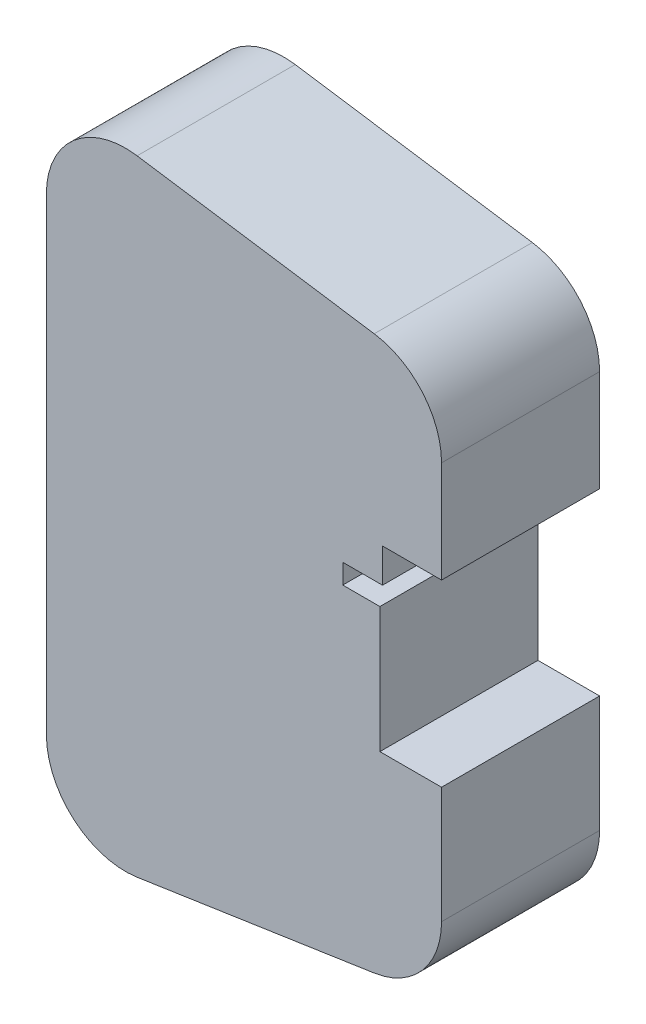
from build123d import *

# Parameters (mm, degrees)
BOSS_EXTRUDE1_DEPTH = 20
SKETCH5_W           = 9
SKETCH5_H           = 1.454272164
CUT_EXTRUDE4_DEPTH  = 10
SKETCH6_R           = 0.5
CUT_EXTRUDE5_DEPTH  = 5
CUT_EXTRUDE6_DEPTH  = 21
SKETCH11_R          = 1
CUT_EXTRUDE7_DEPTH  = 5


with BuildPart() as part:
    # Sketch1 → Boss-Extrude1 (new body)
    with BuildSketch(Plane.XY):
        with BuildLine():
            Line((0, 29.638125792), (0, -29.638125792))
            ThreePointArc((0, -29.638125792), (3.474436626, -37.215527896), (11.483404529, -39.527489321))
            Line((11.483404529, -39.527489321), (41.483404529, -35.027489321))
            ThreePointArc((41.483404529, -35.027489321), (47.577402104, -31.663689166), (50, -25.138125792))
            Line((50, -25.138125792), (50, 25.138125792))
            ThreePointArc((50, 25.138125792), (47.577402104, 31.663689166), (41.483404529, 35.027489321))
            Line((41.483404529, 35.027489321), (11.483404529, 39.527489321))
            ThreePointArc((11.483404529, 39.527489321), (3.474436626, 37.215527896), (0, 29.638125792))
        make_face()
    extrude(amount=BOSS_EXTRUDE1_DEPTH)

    # Sketch5 → Cut-Extrude4 (cut)
    with BuildSketch(Plane.ZY):
        with Locations((10, 16.569972364)):
            Rectangle(SKETCH5_W, SKETCH5_H)
    extrude(amount=-CUT_EXTRUDE4_DEPTH, mode=Mode.SUBTRACT)

    # Sketch6 → Cut-Extrude5 (cut)
    with BuildSketch(Plane.XZ.offset(-17.297108446)):
        with Locations((2.644871575, 10)):
            Circle(SKETCH6_R)
    extrude(amount=-CUT_EXTRUDE5_DEPTH, mode=Mode.SUBTRACT)

    # Sketch9 → Cut-Extrude6 (cut, through all)
    with BuildSketch(Plane.XY.offset(20)):
        Polygon((42.2, 5.497108446), (42.2, -10.402891554), (50, -10.402891554), (50, 12.297108446), (42.53, 12.297108446), (42.53, 7.997108446), (37.5, 7.997108446), (37.5, 5.497108446), align=None)
    extrude(amount=-CUT_EXTRUDE6_DEPTH, mode=Mode.SUBTRACT)

    # Sketch11 → Cut-Extrude7 (cut)
    with BuildSketch(Plane(origin=(0, 7.997108446, 0), x_dir=(-1, 0, 0), z_dir=(0, -1, 0))):
        with Locations((-40.23, -10)):
            Circle(SKETCH11_R)
    extrude(amount=-CUT_EXTRUDE7_DEPTH, mode=Mode.SUBTRACT)


solid = part.part
